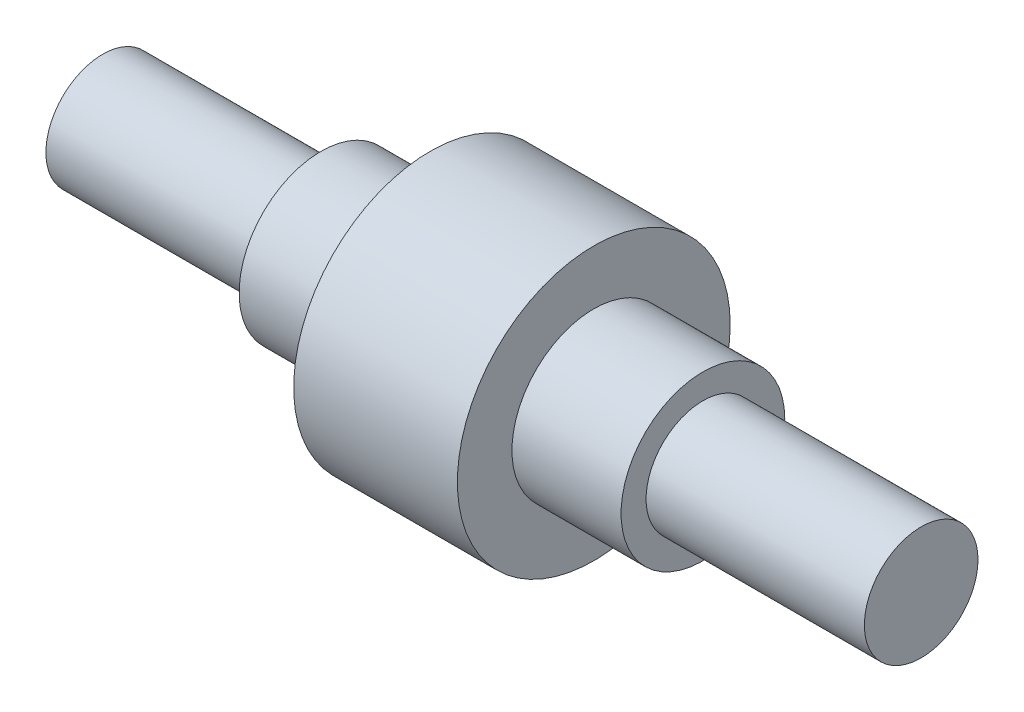
from build123d import *


with BuildPart() as part:
    # Sketch1 → Revolve6 (revolve)
    with BuildSketch(Plane.XY, mode=Mode.PRIVATE) as revolve6_sk:
        Polygon((-30, -50), (30, -50), (30, -30), (70, -30), (70, -20.825600731), (150, -20.825600731), (150, 0), (-150, 0), (-150, -20.825600731), (-70, -20.825600731), (-70, -30), (-30, -30), align=None)
    revolve(revolve6_sk.sketch.rotate(Axis((0, 0, 0), (-1, 0, 0)), 270), axis=Axis((0, 0, 0), (-1, 0, 0)))  # turned: the seam where the file's is


solid = part.part
